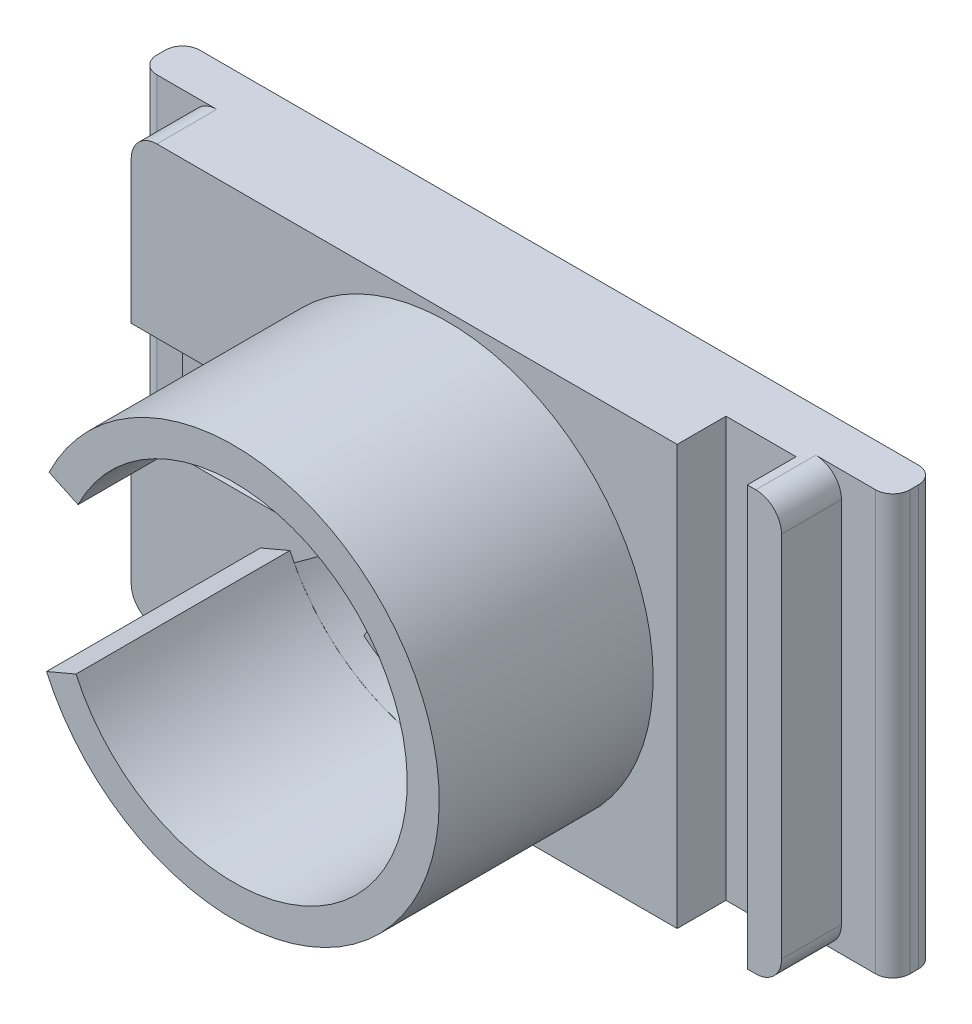
from build123d import *

# Parameters (mm, degrees)
SKETCH1_W           = 65
SKETCH1_H           = 50
BOSS_EXTRUDE1_DEPTH = 12
CUT_EXTRUDE1_DEPTH  = 6
SKETCH3_R           = 9
CUT_EXTRUDE2_DEPTH  = 7
SKETCH4_R           = 20.25
CUT_EXTRUDE3_DEPTH  = 3
SKETCH5_W           = 12
SKETCH5_H           = 50
BOSS_EXTRUDE2_DEPTH = 13
SKETCH6_W           = 8.2
SKETCH6_H           = 50
CUT_EXTRUDE4_DEPTH  = 5.7
SKETCH7_W           = 5
SKETCH7_H           = 50
BOSS_EXTRUDE3_DEPTH = 5
SKETCH8_W           = 5
SKETCH8_H           = 50
BOSS_EXTRUDE4_DEPTH = 5
FILLET1_R           = 2
FILLET2_R           = 2
BOSS_EXTRUDE6_DEPTH = 25
FILLET3_R           = 2
FILLET4_R           = 2
SKETCH10_W          = 1
SKETCH10_H          = 50
CUT_EXTRUDE5_DEPTH  = 7
SKETCH11_W          = 88
SKETCH11_H          = 1
CUT_EXTRUDE6_DEPTH  = 13
FILLET5_R           = 3
FILLET6_R           = 3
FILLET7_R           = 3
FILLET8_R           = 3


with BuildPart() as part:
    # Sketch1 → Boss-Extrude1 (new body)
    with BuildSketch(Plane.XY):
        Rectangle(SKETCH1_W, SKETCH1_H)
    extrude(amount=BOSS_EXTRUDE1_DEPTH)

    # Sketch2 → Cut-Extrude1 (cut)
    with BuildSketch(Plane.XY.offset(12)):
        with BuildLine():
            Line((-0.079165483, -16.163398081), (-1.679165483, -18.934679373))
            ThreePointArc((-1.679165483, -18.934679373), (15.625, -17.537014427), (25.487496091, -3.25))
            Line((25.487496091, -3.25), (22.287496091, -3.25))
            Line((22.287496091, -3.25), (22.287496091, 3.25))
            Line((22.287496091, 3.25), (25.487496091, 3.25))
            ThreePointArc((25.487496091, 3.25), (15.625, 17.537014427), (-1.679165483, 18.934679373))
            Line((-1.679165483, 18.934679373), (-0.079165483, 16.163398081))
            Line((-0.079165483, 16.163398081), (-5.708330608, 12.913398081))
            Line((-5.708330608, 12.913398081), (-7.308330608, 15.684679373))
            ThreePointArc((-7.308330608, 15.684679373), (-11.475017308, 11.041344456), (-14.030488985, 5.35))
            Line((-14.030488985, 5.35), (-14.030488985, -5.35))
            ThreePointArc((-14.030488985, -5.35), (-11.475017308, -11.041344456), (-7.308330608, -15.684679373))
            Line((-7.308330608, -15.684679373), (-5.708330608, -12.913398081))
            Line((-5.708330608, -12.913398081), (-0.079165483, -16.163398081))
        make_face()
        with BuildLine():
            Line((-44.030488985, -5.35), (-14.030488985, -5.35))
            ThreePointArc((-14.030488985, -5.35), (-14.75, 0), (-14.030488985, 5.35))
            Line((-14.030488985, 5.35), (-44.030488985, 5.35))
            Line((-44.030488985, 5.35), (-44.030488985, -5.35))
        make_face()
        with BuildLine():
            ThreePointArc((-14.030488985, 5.35), (-14.75, 0), (-14.030488985, -5.35))
            Line((-14.030488985, -5.35), (-14.030488985, 5.35))
        make_face()
    extrude(amount=-CUT_EXTRUDE1_DEPTH, mode=Mode.SUBTRACT)

    # Sketch3 → Cut-Extrude2 (cut, through all)
    with BuildSketch(Plane.XY.offset(6)):
        with Locations((5.5, 0)):
            Circle(SKETCH3_R)
    extrude(amount=-CUT_EXTRUDE2_DEPTH, mode=Mode.SUBTRACT)

    # Sketch4 → Cut-Extrude3 (cut)
    with BuildSketch(Plane.XY.offset(12)):
        with Locations((5.5, 0)):
            Circle(SKETCH4_R)
    extrude(amount=-CUT_EXTRUDE3_DEPTH, mode=Mode.SUBTRACT)

    # Sketch5 → Boss-Extrude2 (add)
    with BuildSketch(Plane(origin=(32.5, 0, 0), x_dir=(0, 0, -1), z_dir=(1, 0, 0))):
        with Locations((-6, 0)):
            Rectangle(SKETCH5_W, SKETCH5_H)
    extrude(amount=BOSS_EXTRUDE2_DEPTH)

    # Sketch6 → Cut-Extrude4 (cut)
    with BuildSketch(Plane.XY.offset(12)):
        with Locations((36.409019421, 0)):
            Rectangle(SKETCH6_W, SKETCH6_H)
    extrude(amount=-CUT_EXTRUDE4_DEPTH, mode=Mode.SUBTRACT)

    # Sketch7 → Boss-Extrude3 (add)
    with BuildSketch(Plane(origin=(45.5, 0, 0), x_dir=(0, 0, -1), z_dir=(1, 0, 0))):
        with Locations((-2.5, 0)):
            Rectangle(SKETCH7_W, SKETCH7_H)
    extrude(amount=BOSS_EXTRUDE3_DEPTH)

    # Sketch8 → Boss-Extrude4 (add)
    with BuildSketch(Plane.ZY.offset(32.5)):
        with Locations((2.5, 0)):
            Rectangle(SKETCH8_W, SKETCH8_H)
    extrude(amount=BOSS_EXTRUDE4_DEPTH)

    # Fillet1
    fillet1_edges = [part.edges().sort_by_distance(p)[0] for p in [
        (50.5, 0, 5),
    ]]
    fillet(fillet1_edges, radius=FILLET1_R)

    # Fillet2
    fillet2_edges = [part.edges().sort_by_distance(p)[0] for p in [
        (-37.5, 0, 5),
    ]]
    fillet(fillet2_edges, radius=FILLET2_R)

    # Sketch9 → Boss-Extrude6 (add)
    with BuildSketch(Plane.XY.offset(12)):
        with BuildLine():
            Line((-16.092960793, 10.475879161), (-12.705503837, 8.889726094))
            ThreePointArc((-12.705503837, 8.889726094), (10.062022154, 19.739694878), (25.76, 0))
            ThreePointArc((25.76, 0), (9.783964079, -19.801900206), (-12.948317056, -8.374198339))
            Line((-12.948317056, -8.374198339), (-16.391781636, -9.83615254))
            ThreePointArc((-16.391781636, -9.83615254), (10.529773391, -23.467027499), (29.5, 0))
            ThreePointArc((29.5, 0), (10.874427457, 23.390500839), (-16.092960793, 10.475879161))
        make_face()
    extrude(amount=BOSS_EXTRUDE6_DEPTH)

    # Fillet3
    fillet3_edges = [part.edges().sort_by_distance(p)[0] for p in [
        (-37.5, 0, 0),
    ]]
    fillet(fillet3_edges, radius=FILLET3_R)

    # Fillet4
    fillet4_edges = [part.edges().sort_by_distance(p)[0] for p in [
        (50.5, 0, 0),
    ]]
    fillet(fillet4_edges, radius=FILLET4_R)

    # Sketch10 → Cut-Extrude5 (cut)
    with BuildSketch(Plane.XY.offset(12)):
        with Locations((45, 0)):
            Rectangle(SKETCH10_W, SKETCH10_H)
        with Locations((-32, 0)):
            Rectangle(SKETCH10_W, SKETCH10_H)
    extrude(amount=-CUT_EXTRUDE5_DEPTH, mode=Mode.SUBTRACT)

    # Sketch11 → Cut-Extrude6 (cut, through all)
    with BuildSketch(Plane.XY.offset(12)):
        with Locations((6.5, -24.5)):
            Rectangle(SKETCH11_W, SKETCH11_H)
    extrude(amount=-CUT_EXTRUDE6_DEPTH, mode=Mode.SUBTRACT)

    # Fillet5
    fillet5_edges = [part.edges().sort_by_distance(p)[0] for p in [
        (44.5, -24, 8.5),
    ]]
    fillet(fillet5_edges, radius=FILLET5_R)

    # Fillet6
    fillet6_edges = [part.edges().sort_by_distance(p)[0] for p in [
        (44.5, 25, 8.5),
    ]]
    fillet(fillet6_edges, radius=FILLET6_R)

    # Fillet7
    fillet7_edges = [part.edges().sort_by_distance(p)[0] for p in [
        (-31.5, 25, 8.5),
    ]]
    fillet(fillet7_edges, radius=FILLET7_R)

    # Fillet8
    fillet8_edges = [part.edges().sort_by_distance(p)[0] for p in [
        (-31.5, -24, 8.5),
    ]]
    fillet(fillet8_edges, radius=FILLET8_R)


solid = part.part
